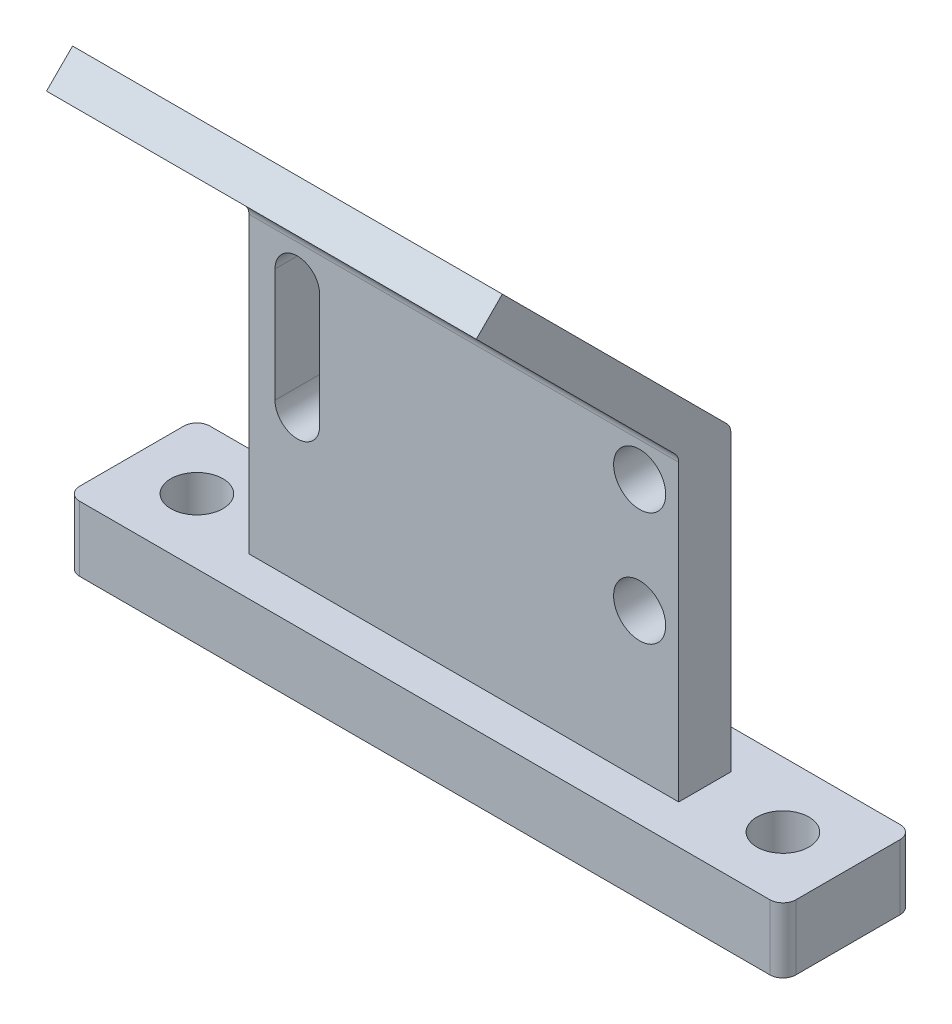
from build123d import *

# Parameters (mm, degrees)
EXTRUDE_2_DEPTH     = 5
SKETCH_4_W          = 33
SKETCH_4_H          = 4
EXTRUDE_3_DEPTH     = 23
EXTRUDE_4_DEPTH     = 33
SKETCH_11_R         = 2
CUT_EXTRUDE_1_DEPTH = 14
CUT_EXTRUDE_2_DEPTH = 33
SKETCH_17_R         = 2
CUT_EXTRUDE_3_DEPTH = 5
SKETCH_19_W         = 37
SKETCH_19_H         = 10
EXTRUDE_5_DEPTH     = 5


with BuildPart() as part:
    # 草图1 → 凸台-拉伸2 (new body)
    with BuildSketch(Plane(origin=(0, 0, 0), x_dir=(1, 0, 0), z_dir=(0, 1, 0))):
        with BuildLine():
            Line((26.533821687, -5), (18.533821687, -5))
            ThreePointArc((18.533821687, -5), (17.826714906, -4.707106781), (17.533821687, -4))
            Line((17.533821687, -4), (17.533821687, -3))
            ThreePointArc((17.533821687, -3), (17.240928468, -2.292893219), (16.533821687, -2))
            Line((16.533821687, -2), (-16.466178313, -2))
            ThreePointArc((-16.466178313, -2), (-17.173285094, -2.292893219), (-17.466178313, -3))
            Line((-17.466178313, -3), (-17.466178313, -4))
            ThreePointArc((-17.466178313, -4), (-17.759071532, -4.707106781), (-18.466178313, -5))
            Line((-18.466178313, -5), (-26.466178313, -5))
            ThreePointArc((-26.466178313, -5), (-27.173285094, -4.707106781), (-27.466178313, -4))
            Line((-27.466178313, -4), (-27.466178313, 4))
            ThreePointArc((-27.466178313, 4), (-27.173285094, 4.707106781), (-26.466178313, 5))
            Line((-26.466178313, 5), (-18.466178313, 5))
            ThreePointArc((-18.466178313, 5), (-17.759071532, 4.707106781), (-17.466178313, 4))
            Line((-17.466178313, 4), (-17.466178313, 3))
            ThreePointArc((-17.466178313, 3), (-17.173285094, 2.292893219), (-16.466178313, 2))
            Line((-16.466178313, 2), (16.533821687, 2))
            ThreePointArc((16.533821687, 2), (17.240928468, 2.292893219), (17.533821687, 3))
            Line((17.533821687, 3), (17.533821687, 4))
            ThreePointArc((17.533821687, 4), (17.826714906, 4.707106781), (18.533821687, 5))
            Line((18.533821687, 5), (26.533821687, 5))
            ThreePointArc((26.533821687, 5), (27.240928468, 4.707106781), (27.533821687, 4))
            Line((27.533821687, 4), (27.533821687, -4))
            ThreePointArc((27.533821687, -4), (27.240928468, -4.707106781), (26.533821687, -5))
        make_face()
    extrude(amount=EXTRUDE_2_DEPTH)

    # 草图4 → 凸台-拉伸3 (add)
    with BuildSketch(Plane(origin=(0, 5, 0), x_dir=(1, 0, 0), z_dir=(0, 1, 0))):
        with Locations((0.033821687, 0)):
            Rectangle(SKETCH_4_W, SKETCH_4_H)
    extrude(amount=EXTRUDE_3_DEPTH)

    # 草图5 → 凸台-拉伸4 (add)
    with BuildSketch(Plane.ZY.offset(16.466178313)):
        with BuildLine():
            ThreePointArc((2, 27.585786438), (2.076120467, 27.96846987), (2.292893219, 28.292893219))
            Line((2.292893219, 28.292893219), (17.54448252, 43.54448252))
            Line((17.54448252, 43.54448252), (15.54448252, 45.54448252))
            Line((15.54448252, 45.54448252), (-1.707106781, 28.292893219))
            ThreePointArc((-1.707106781, 28.292893219), (-1.821797126, 28.155566643), (-1.910179721, 28))
            Line((-1.910179721, 28), (2, 28))
            Line((2, 28), (2, 27.585786438))
        make_face()
    extrude(amount=-EXTRUDE_4_DEPTH)

    # 草图11 → 切除-拉伸1 (cut)
    with BuildSketch(Plane.XY.offset(2)):
        with Locations((13.533821687, 24.952009276)):
            Circle(SKETCH_11_R)
        with Locations((13.533821687, 16.219563599)):
            Circle(SKETCH_11_R)
        with BuildLine():
            Line((-11.034001398, 24.952009276), (-11.034001398, 16.219563599))
            ThreePointArc((-11.034001398, 16.219563599), (-12.750089855, 14.503475142), (-14.466178313, 16.219563599))
            Line((-14.466178313, 16.219563599), (-14.466178313, 24.952009276))
            ThreePointArc((-14.466178313, 24.952009276), (-12.750089855, 26.668097734), (-11.034001398, 24.952009276))
        make_face()
    extrude(amount=-CUT_EXTRUDE_1_DEPTH, mode=Mode.SUBTRACT)

    # 草图16 → 切除-拉伸2 (cut)
    with BuildSketch(Plane.ZY.offset(16.466178313)):
        with BuildLine():
            Line((-1.910179721, 28), (-2, 28))
            Line((-2, 28), (-2, 27.585786438))
            ThreePointArc((-2, 27.585786438), (-1.97728699, 27.797706563), (-1.910179721, 28))
        make_face()
    extrude(amount=-CUT_EXTRUDE_2_DEPTH, mode=Mode.SUBTRACT)

    # 草图17 → 切除-拉伸3 (cut)
    with BuildSketch(Plane(origin=(0, 5, 0), x_dir=(1, 0, 0), z_dir=(0, 1, 0))):
        with Locations((22.533821687, 0)):
            Circle(SKETCH_17_R)
        with Locations((-22.466178313, 0)):
            Circle(SKETCH_17_R)
    extrude(amount=-CUT_EXTRUDE_3_DEPTH, mode=Mode.SUBTRACT)

    # 草图19 → 凸台-拉伸5 (add)
    with BuildSketch(Plane(origin=(0, 5, 0), x_dir=(1, 0, 0), z_dir=(0, 1, 0))):
        with Locations((0.033821687, 0)):
            Rectangle(SKETCH_19_W, SKETCH_19_H)
    extrude(amount=-EXTRUDE_5_DEPTH)


solid = part.part
